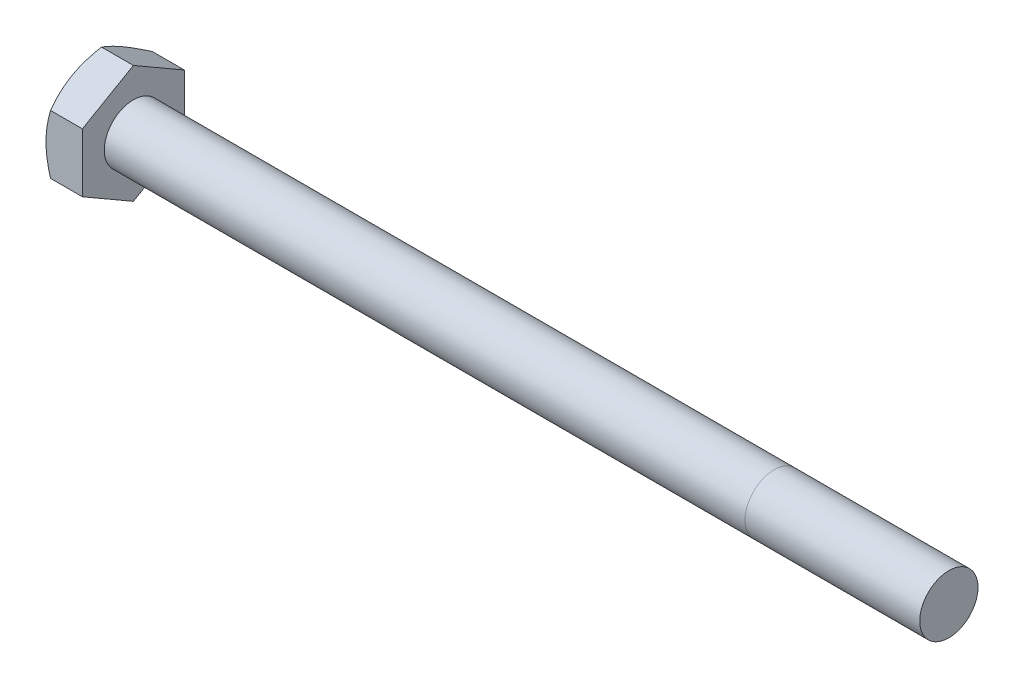
from build123d import *

# Parameters (mm, degrees)
SKETCH5_R           = 3.175
BOSS_EXTRUDE3_DEPTH = 88.9
BOSS_EXTRUDE4_DEPTH = 3.96875
SKETCH8_OUTSIDE_W   = 357.164
SKETCH8_OUTSIDE_H   = 358.884
SKETCH8_OUTSIDE_R   = 5.55625
CUT_EXTRUDE3_DEPTH  = 93.86875
CUT_EXTRUDE3_TAPER  = 60
CUT_EXTRUDE4_DEPTH  = 0.254
CIRPATTERN1_COUNT   = 3


with BuildPart() as part:
    # Sketch5 → Boss-Extrude3 (new body)
    with BuildSketch(Plane(origin=(46.434375, 0, 0), x_dir=(0, 0, -1), z_dir=(1, 0, 0))):
        Circle(SKETCH5_R)
    extrude(amount=-BOSS_EXTRUDE3_DEPTH)

    # Sketch11 → Revolve1 (revolve)
    with BuildSketch(Plane.XY):
        Polygon((-42.465625, 3.175), (-42.465625, 0), (30.559375, 0), (27.384375, 3.175), align=None)
    revolve(axis=Axis((-42.465625, 0, 0), (1, 0, 0)))

    # Sketch6 → Boss-Extrude4 (add)
    with BuildSketch(Plane.ZY.offset(42.465625)):
        Polygon((5.55625, 3.207902433), (0, 6.415804866), (-5.55625, 3.207902433), (-5.55625, -3.207902433), (0, -6.415804866), (5.55625, -3.207902433), align=None)
    extrude(amount=BOSS_EXTRUDE4_DEPTH)

    # Sketch8 outside → Cut-Extrude3 (cut, through all)
    with BuildSketch(Plane.ZY.offset(46.434375)):
        Rectangle(SKETCH8_OUTSIDE_W, SKETCH8_OUTSIDE_H)
        Circle(SKETCH8_OUTSIDE_R, mode=Mode.SUBTRACT)
    extrude(amount=-CUT_EXTRUDE3_DEPTH, taper=CUT_EXTRUDE3_TAPER, mode=Mode.SUBTRACT)

    # Sketch12 → Cut-Extrude4 (cut)
    with BuildSketch(Plane.ZY.offset(46.434375)):
        with BuildLine():
            Line((0.1666875, 4.2783125), (0.1666875, 2.3891875))
            ThreePointArc((0.1666875, 2.3891875), (0, 2.2225), (-0.1666875, 2.3891875))
            Line((-0.1666875, 2.3891875), (-0.1666875, 4.2783125))
            ThreePointArc((-0.1666875, 4.2783125), (0, 4.445), (0.1666875, 4.2783125))
        make_face()
    cut_extrude4 = extrude(amount=-CUT_EXTRUDE4_DEPTH, mode=Mode.SUBTRACT)

    # CirPattern1: Cut-Extrude4 ×3 about axis
    cirpattern1_axis = Axis((0, 0, 0), (1, 0, 0))
    for i in range(1, CIRPATTERN1_COUNT):
        add(cut_extrude4.rotate(cirpattern1_axis, i * 360 / CIRPATTERN1_COUNT), mode=Mode.SUBTRACT)


solid = part.part
